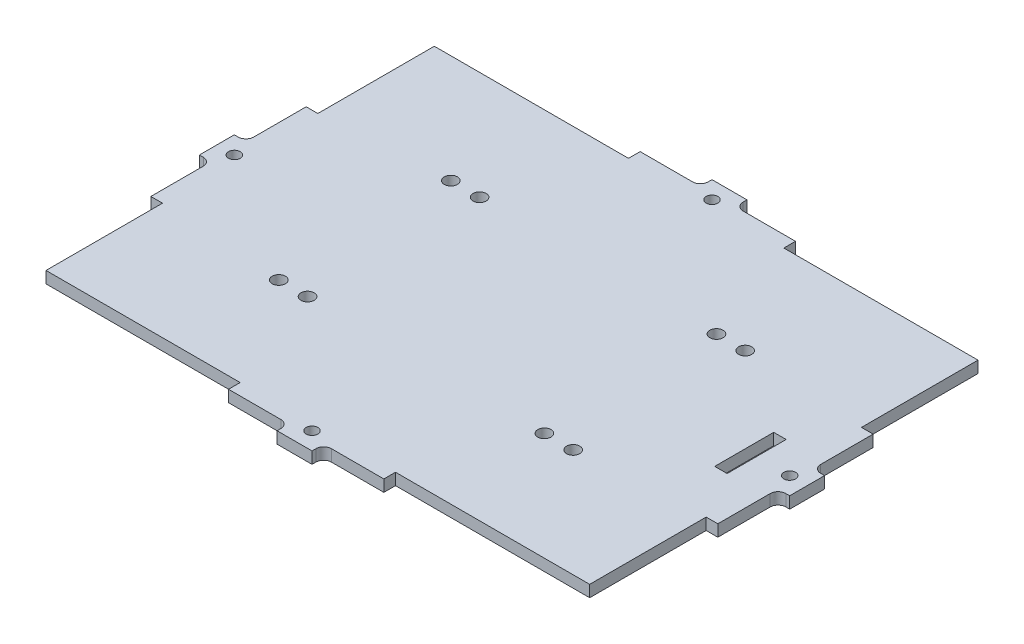
from build123d import *

# Parameters (mm, degrees)
ESBO_O1_W                = 140
ESBO_O1_H                = 100
RESSALTO_EXTRUS_O1_DEPTH = 1.5
RESSALTO_EXTRUS_O2_DEPTH = 3
ESBO_O2_R                = 1.5
CORTE_EXTRUS_O1_DEPTH    = 4
SKETCH1_R                = 1.7
CUT_EXTRUDE1_DEPTH       = 1
CUT_EXTRUDE1_DEPTH_BACK  = 4
SKETCH2_W                = 3.2
SKETCH2_H                = 15.2
CUT_EXTRUDE3_DEPTH       = 2.5
CUT_EXTRUDE3_DEPTH_BACK  = 2.5


with BuildPart() as part:
    # Esboço1 → Ressalto-extrusão1 (new body, symmetric)
    with BuildSketch(Plane(origin=(0, 0, 0), x_dir=(1, 0, 0), z_dir=(0, 1, 0))):
        Rectangle(ESBO_O1_W, ESBO_O1_H)
    extrude(amount=RESSALTO_EXTRUS_O1_DEPTH, both=True)

    # Esboço4 → Ressalto-extrusão2 (add, through all)
    with BuildSketch(Plane(origin=(0, 1.5, 0), x_dir=(1, 0, 0), z_dir=(0, 1, 0))):
        with BuildLine():
            Line((6.5, 53), (20, 53))
            Line((20, 53), (20, 50))
            Line((20, 50), (-20, 50))
            Line((-20, 50), (-20, 53))
            Line((-20, 53), (-6.5, 53))
            ThreePointArc((-6.5, 53), (-5.085786438, 53.585786438), (-4.5, 55))
            Line((-4.5, 55), (-4.5, 56))
            Line((-4.5, 56), (4.5, 56))
            Line((4.5, 56), (4.5, 55))
            ThreePointArc((4.5, 55), (5.085786438, 53.585786438), (6.5, 53))
        make_face()
        with BuildLine():
            Line((-76, 4.5), (-76, -4.5))
            Line((-76, -4.5), (-75, -4.5))
            ThreePointArc((-75, -4.5), (-73.585786438, -5.085786438), (-73, -6.5))
            Line((-73, -6.5), (-73, -20))
            Line((-73, -20), (-70, -20))
            Line((-70, -20), (-70, 20))
            Line((-70, 20), (-73, 20))
            Line((-73, 20), (-73, 6.5))
            ThreePointArc((-73, 6.5), (-73.585786438, 5.085786438), (-75, 4.5))
            Line((-75, 4.5), (-76, 4.5))
        make_face()
        with BuildLine():
            Line((4.5, -56), (4.5, -55))
            ThreePointArc((4.5, -55), (5.085786438, -53.585786438), (6.5, -53))
            Line((6.5, -53), (20, -53))
            Line((20, -53), (20, -50))
            Line((20, -50), (-20, -50))
            Line((-20, -50), (-20, -53))
            Line((-20, -53), (-6.5, -53))
            ThreePointArc((-6.5, -53), (-5.085786438, -53.585786438), (-4.5, -55))
            Line((-4.5, -55), (-4.5, -56))
            Line((-4.5, -56), (4.5, -56))
        make_face()
        with BuildLine():
            Line((70, 20), (73, 20))
            Line((73, 20), (73, 6.5))
            ThreePointArc((73, 6.5), (73.585786438, 5.085786438), (75, 4.5))
            Line((75, 4.5), (76, 4.5))
            Line((76, 4.5), (76, -4.5))
            Line((76, -4.5), (75, -4.5))
            ThreePointArc((75, -4.5), (73.585786438, -5.085786438), (73, -6.5))
            Line((73, -6.5), (73, -20))
            Line((73, -20), (70, -20))
            Line((70, -20), (70, 20))
        make_face()
    extrude(amount=-RESSALTO_EXTRUS_O2_DEPTH)

    # Esboço2 → Corte-extrusão1 (cut, through all)
    with BuildSketch(Plane(origin=(0, 1.5, 0), x_dir=(1, 0, 0), z_dir=(0, 1, 0))):
        with Locations((0, -51.5)):
            Circle(ESBO_O2_R)
        with Locations((0, 51.5)):
            Circle(ESBO_O2_R)
        with Locations((71.5, 0)):
            Circle(ESBO_O2_R)
        with Locations((-71.5, 0)):
            Circle(ESBO_O2_R)
    extrude(amount=-CORTE_EXTRUS_O1_DEPTH, mode=Mode.SUBTRACT)

    # Sketch1 → Cut-Extrude1 (cut, two sides)
    with BuildSketch(Plane(origin=(0, 1.5, 0), x_dir=(1, 0, 0), z_dir=(0, 1, 0))) as cut_extrude1_sk:
        with Locations((30.5, -22.15)):
            Circle(SKETCH1_R)
        with Locations((37.9, -22.15)):
            Circle(SKETCH1_R)
        with Locations((37.9, 22.15)):
            Circle(SKETCH1_R)
        with Locations((30.5, 22.15)):
            Circle(SKETCH1_R)
        with Locations((-30.5, 22.15)):
            Circle(SKETCH1_R)
        with Locations((-37.9, 22.15)):
            Circle(SKETCH1_R)
        with Locations((-37.9, -22.15)):
            Circle(SKETCH1_R)
        with Locations((-30.5, -22.15)):
            Circle(SKETCH1_R)
    extrude(amount=CUT_EXTRUDE1_DEPTH, mode=Mode.SUBTRACT)
    extrude(cut_extrude1_sk.sketch, amount=-CUT_EXTRUDE1_DEPTH_BACK, mode=Mode.SUBTRACT)

    # Sketch2 → Cut-Extrude3 (cut, two sides)
    with BuildSketch(Plane(origin=(0, 0, 0), x_dir=(1, 0, 0), z_dir=(0, 1, 0))) as cut_extrude3_sk:
        with Locations((61.4, 0)):
            Rectangle(SKETCH2_W, SKETCH2_H)
    extrude(amount=CUT_EXTRUDE3_DEPTH, mode=Mode.SUBTRACT)
    extrude(cut_extrude3_sk.sketch, amount=-CUT_EXTRUDE3_DEPTH_BACK, mode=Mode.SUBTRACT)


solid = part.part
